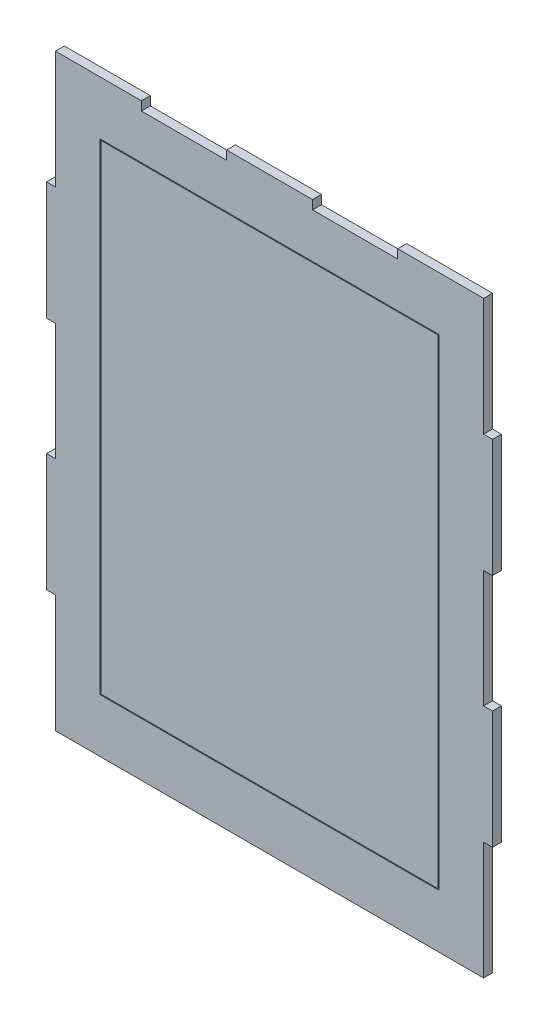
from build123d import *

# Parameters (mm, degrees)
ESQUISSE1_W          = 189
ESQUISSE1_H          = 269
BOSS_EXTRU_1_DEPTH   = 5
ESQUISSE1_W_2        = 190
ESQUISSE1_H_2        = 270
BOSS_EXTRU_1_2_DEPTH = 5


with BuildPart() as part:
    # Esquisse1 → Boss.-Extru.1 (new body)
    with BuildSketch(Plane.XY):
        with Locations((125, 165)):
            Rectangle(ESQUISSE1_W, ESQUISSE1_H)
    extrude(amount=BOSS_EXTRU_1_DEPTH)


with BuildPart() as body_2:
    # Esquisse1 → Boss.-Extru.1 2 (new body)
    with BuildSketch(Plane.XY):
        Polygon((196.9, 325.1), (196.9, 330.1), (245.1, 330.1), (245.1, 264.1), (250.1, 264.1), (250.1, 197.9), (245.1, 197.9), (245.1, 132.1), (250.1, 132.1), (250.1, 65.9), (245.1, 65.9), (245.1, -0.1), (4.9, -0.1), (4.9, 65.9), (-0.1, 65.9), (-0.1, 132.1), (4.9, 132.1), (4.9, 197.9), (-0.1, 197.9), (-0.1, 264.1), (4.9, 264.1), (4.9, 330.1), (53.1, 330.1), (53.1, 325.1), (100.9, 325.1), (100.9, 330.1), (149.1, 330.1), (149.1, 325.1), align=None)
        with Locations((125, 165)):
            Rectangle(ESQUISSE1_W_2, ESQUISSE1_H_2, mode=Mode.SUBTRACT)
    extrude(amount=BOSS_EXTRU_1_2_DEPTH)


solid = Compound([part.part, body_2.part])
